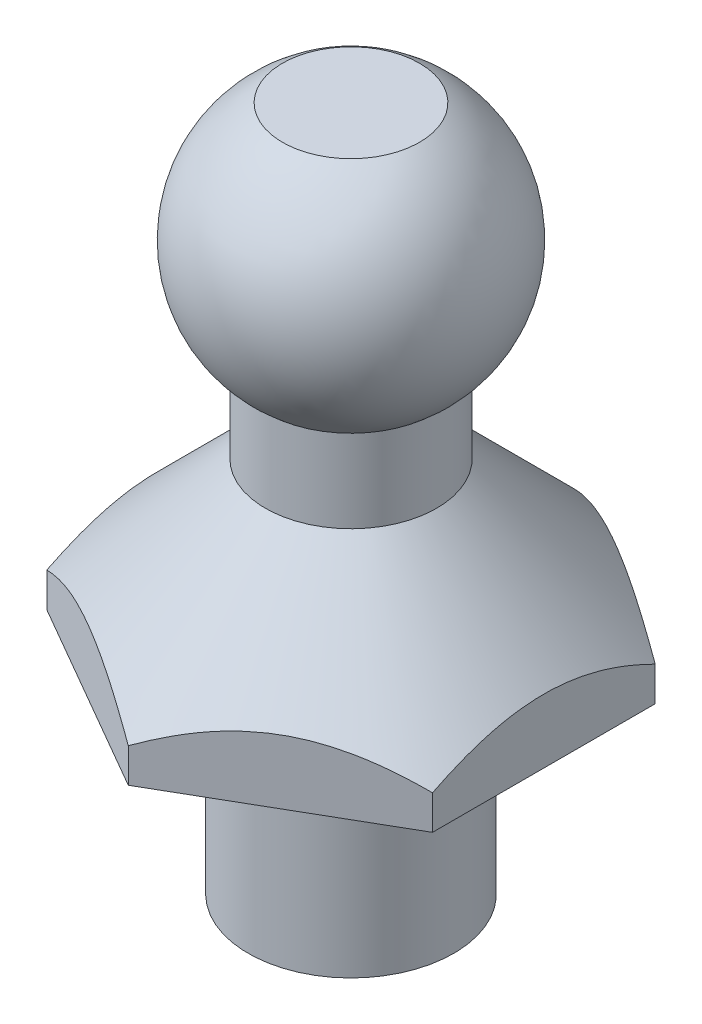
from build123d import *

# Parameters (mm, degrees)
SKETCH3_OUTSIDE_W  = 11.216
SKETCH3_OUTSIDE_H  = 11.216
CUT_EXTRUDE1_DEPTH = 8


with BuildPart() as part:
    # Sketch1 → Revolve3 (revolve)
    with BuildSketch(Plane.XY):
        with BuildLine():
            ThreePointArc((1, 10), (1.994262201, 8.419337011), (1.25, 6.706699693))
            Line((1.25, 6.706699693), (1.25, 5.5))
            Line((1.25, 5.5), (0, 5.5))
            Line((0, 5.5), (0, 10))
            Line((0, 10), (1, 10))
        make_face()
        Polygon((0, 0), (0, 5.5), (1.25, 5.5), (3.25, 3.5), (3.25, 3), (1.5, 3), (1.5, 0), align=None)
    revolve(axis=Axis((0, 5.5, 0), (0, 1, 0)))

    # Sketch3 outside → Cut-Extrude1 (cut, through all)
    with BuildSketch(Plane.XZ.offset(-3)):
        Rectangle(SKETCH3_OUTSIDE_W, SKETCH3_OUTSIDE_H)
        Polygon((0, 3.25), (-2.814582562, 1.625), (-2.814582562, -1.625), (0, -3.25), (2.814582562, -1.625), (2.814582562, 1.625), align=None, mode=Mode.SUBTRACT)
    extrude(amount=-CUT_EXTRUDE1_DEPTH, mode=Mode.SUBTRACT)


solid = part.part
